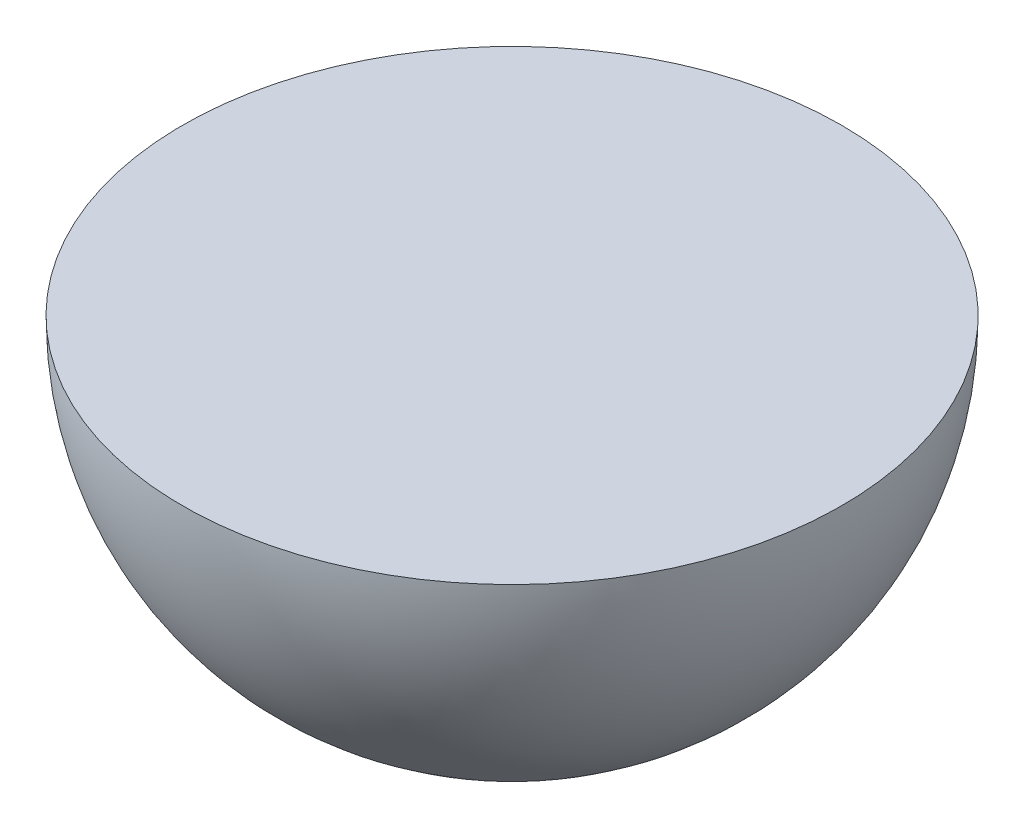
from build123d import *

# Parameters (mm, degrees)
REVOLVE1_ANGLE = 180


with BuildPart() as part:
    # Sketch1 → Revolve1 (revolve)
    with BuildSketch(Plane(origin=(0, 0, 0), x_dir=(1, 0, 0), z_dir=(0, 1, 0))):
        with BuildLine():
            Line((-2.5, 0), (2.5, 0))
            ThreePointArc((2.5, 0), (0, 2.5), (-2.5, 0))
        make_face()
    revolve(axis=Axis((-2.5, 0, 0), (-1, 0, 0)), revolution_arc=REVOLVE1_ANGLE)


solid = part.part
